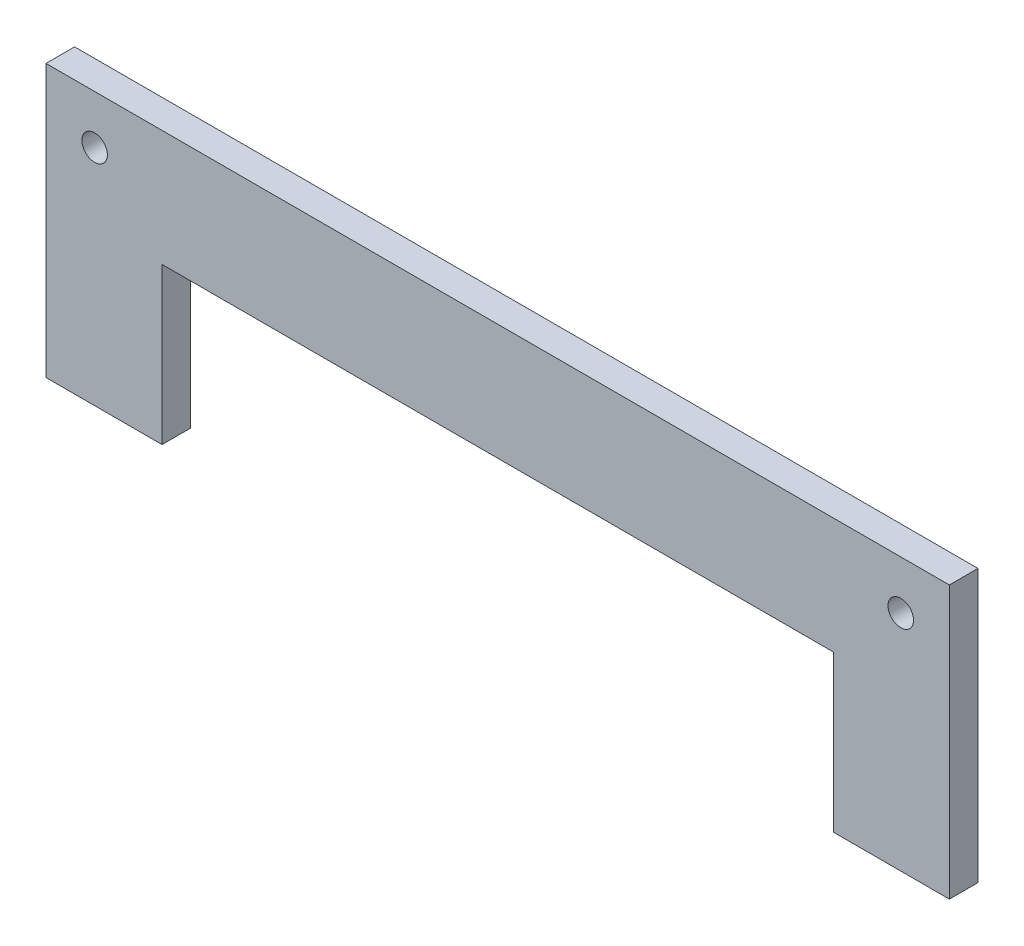
from build123d import *

# Parameters (mm, degrees)
SKETCH1_R           = 1.415
BOSS_EXTRUDE1_DEPTH = 3.175


with BuildPart() as part:
    # Sketch1 → Boss-Extrude1 (new body)
    with BuildSketch(Plane.XY):
        Polygon((50.085, -30.085), (50.085, 0.085), (-50.085, 0.085), (-50.085, -30.085), (-37.215, -30.085), (-37.215, -12.785), (37.215, -12.785), (37.215, -30.085), align=None)
        with Locations((-44.696699141, -5.303300859)):
            Circle(SKETCH1_R, mode=Mode.SUBTRACT)
        with Locations((44.696699141, -5.303300859)):
            Circle(SKETCH1_R, mode=Mode.SUBTRACT)
    extrude(amount=BOSS_EXTRUDE1_DEPTH)


solid = part.part
